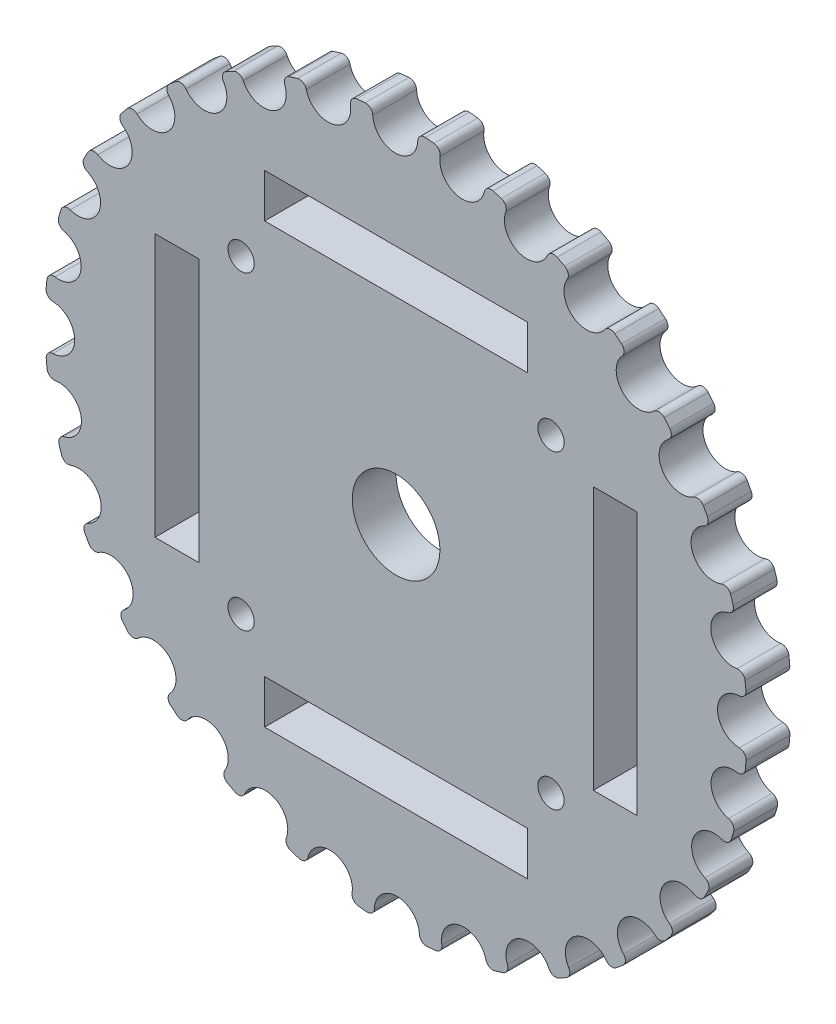
from build123d import *

# Parameters (mm, degrees)
SCHIZZO1_R                   = 40.062660939
ESTRUSIONE_ESTRUSIONE1_DEPTH = 5
SCHIZZO2_R                   = 2.57
TAGLIO_ESTRUSIONE1_DEPTH     = 6
RACCORDO1_R                  = 0.8
SCHIZZO3_R                   = 5
TAGLIO_ESTRUSIONE2_DEPTH     = 6.0000001
SCHIZZO4_R                   = 1.5
SCHIZZO4_W                   = 30
SCHIZZO4_H                   = 5
SCHIZZO4_W_2                 = 5
SCHIZZO4_H_2                 = 30
TAGLIO_ESTRUSIONE3_DEPTH     = 6.0000001


with BuildPart() as part:
    # Schizzo1 → Estrusione-Estrusione1 (new body)
    with BuildSketch(Plane.XY):
        Circle(SCHIZZO1_R)
    extrude(amount=ESTRUSIONE_ESTRUSIONE1_DEPTH)

    # Schizzo2 → Taglio-Estrusione1 (cut, through all)
    with BuildSketch(Plane.XY):
        with Locations((-0.093519434, 39.234888545)):
            Circle(SCHIZZO2_R)
        with Locations((7.562660721, 38.499613085)):
            Circle(SCHIZZO2_R)
        with Locations((14.928284395, 36.284819086)):
            Circle(SCHIZZO2_R)
        with Locations((21.7202948, 32.675619837)):
            Circle(SCHIZZO2_R)
        with Locations((27.677678787, 27.810714843)):
            Circle(SCHIZZO2_R)
        with Locations((32.571497429, 21.877059674)):
            Circle(SCHIZZO2_R)
        with Locations((36.21368402, 15.102681371)):
            Circle(SCHIZZO2_R)
        with Locations((38.464271373, 7.747915492)):
            Circle(SCHIZZO2_R)
        with Locations((39.236770677, 0.095401566)):
            Circle(SCHIZZO2_R)
        with Locations((38.501495217, -7.560778589)):
            Circle(SCHIZZO2_R)
        with Locations((36.286701218, -14.926402263)):
            Circle(SCHIZZO2_R)
        with Locations((32.677501969, -21.718412668)):
            Circle(SCHIZZO2_R)
        with Locations((27.812596975, -27.675796655)):
            Circle(SCHIZZO2_R)
        with Locations((21.878941807, -32.569615297)):
            Circle(SCHIZZO2_R)
        with Locations((15.104563503, -36.211801888)):
            Circle(SCHIZZO2_R)
        with Locations((7.749797624, -38.462389241)):
            Circle(SCHIZZO2_R)
        with Locations((0.097283698, -39.234888545)):
            Circle(SCHIZZO2_R)
        with Locations((-7.558896457, -38.499613085)):
            Circle(SCHIZZO2_R)
        with Locations((-14.92452013, -36.284819086)):
            Circle(SCHIZZO2_R)
        with Locations((-21.716530536, -32.675619837)):
            Circle(SCHIZZO2_R)
        with Locations((-27.673914523, -27.810714843)):
            Circle(SCHIZZO2_R)
        with Locations((-32.567733165, -21.877059674)):
            Circle(SCHIZZO2_R)
        with Locations((-36.209919756, -15.102681371)):
            Circle(SCHIZZO2_R)
        with Locations((-38.460507109, -7.747915492)):
            Circle(SCHIZZO2_R)
        with Locations((-39.233006413, -0.095401566)):
            Circle(SCHIZZO2_R)
        with Locations((-38.497730953, 7.560778589)):
            Circle(SCHIZZO2_R)
        with Locations((-36.282936953, 14.926402263)):
            Circle(SCHIZZO2_R)
        with Locations((-32.673737705, 21.718412668)):
            Circle(SCHIZZO2_R)
        with Locations((-27.808832711, 27.675796655)):
            Circle(SCHIZZO2_R)
        with Locations((-21.875177542, 32.569615297)):
            Circle(SCHIZZO2_R)
        with Locations((-15.100799239, 36.211801888)):
            Circle(SCHIZZO2_R)
        with Locations((-7.74603336, 38.462389241)):
            Circle(SCHIZZO2_R)
    extrude(amount=TAGLIO_ESTRUSIONE1_DEPTH, mode=Mode.SUBTRACT)

    # Raccordo1
    raccordo1_edges = [part.edges().sort_by_distance(p)[0] for p in [
        (31.942109789, -24.180951671, 2.5),
        (34.663171869, -20.086844389, 2.5),
        (26.611153993, -29.94767578, 2.5),
        (30.078524478, -26.463166227, 2.5),
        (20.257609847, -34.563652076, 2.5),
        (24.337986317, -31.822621255, 2.5),
        (13.125595942, -37.851493137, 2.5),
        (17.662122402, -35.959230161, 2.5),
        (5.489149667, -39.684833847, 2.5),
        (10.307451953, -38.713992764, 2.5),
        (-2.358297523, -39.993189849, 2.5),
        (2.556595149, -39.981003273, 2.5),
        (-10.115191512, -38.764670799, 2.5),
        (-5.292585413, -39.711526553, 2.5),
        (-17.483441203, -36.046443447, 2.5),
        (-12.938431635, -37.915877787, 2.5),
        (10.11906027, 38.763661086, 2.5),
        (-24.179873687, -31.942925821, 2.5),
        (-20.087085287, -34.663032271, 2.5),
        (5.296099227, 39.711058088, 2.5),
        (-29.947118726, -26.611780879, 2.5),
        (-26.46378579, -30.077979373, 2.5),
        (-34.563503922, -20.257862625, 2.5),
        (-31.823435482, -24.336921654, 2.5),
        (-37.85157961, -13.125346568, 2.5),
        (-35.960025392, -17.660503258, 2.5),
        (-39.684944931, -5.488346503, 2.5),
        (-38.714558233, -10.305327861, 2.5),
        (-39.993111736, 2.359621835, 2.5),
        (-39.981163224, -2.554092556, 2.5),
        (-38.764218427, 10.11692499, 2.5),
        (-39.711167015, 5.295282413, 2.5),
        (-36.045488681, 17.485409554, 2.5),
        (-37.914963935, 12.941109354, 2.5),
        (-31.941416979, 24.181866819, 2.5),
        (-34.661613715, 20.089533001, 2.5),
        (-26.609750631, 29.948922733, 2.5),
        (-30.076182583, 26.46582783, 2.5),
        (17.487042146, 36.044696676, 2.5),
        (-20.255423044, 34.564933659, 2.5),
        (-24.334930677, 31.824957981, 2.5),
        (12.941372162, 37.914874232, 2.5),
        (-13.122672082, 37.852506904, 2.5),
        (-17.658531673, 35.9609936, 2.5),
        (-5.485647344, 39.685318126, 2.5),
        (-10.303586252, 38.715021785, 2.5),
        (24.182945141, 31.940600586, 2.5),
        (20.089291397, 34.661753745, 2.5),
        (29.949479628, 26.60912384, 2.5),
        (26.465208159, 30.076727857, 2.5),
        (34.565081384, 20.255170956, 2.5),
        (31.824144106, 24.335995015, 2.5),
        (37.852420015, 13.122922714, 2.5),
        (35.960198926, 17.660149906, 2.5),
        (39.685206872, 5.486452137, 2.5),
        (38.714456796, 10.305708927, 2.5),
        (39.993041872, -2.360805648, 2.5),
        (39.981088796, 2.555257362, 2.5),
        (2.36213165, 39.992963576, 2.5),
        (38.764113933, -10.117325363, 2.5),
        (39.711417465, -5.293403861, 2.5),
        (-2.552756457, 39.981248554, 2.5),
        (36.045652002, -17.48507287, 2.5),
        (37.915787671, -12.938695713, 2.5),
    ]]
    fillet(raccordo1_edges, radius=RACCORDO1_R)

    # Schizzo3 → Taglio-Estrusione2 (cut, through all)
    with BuildSketch(Plane.XY):
        Circle(SCHIZZO3_R)
    extrude(amount=TAGLIO_ESTRUSIONE2_DEPTH, mode=Mode.SUBTRACT)

    # Schizzo4 → Taglio-Estrusione3 (cut, through all)
    with BuildSketch(Plane.XY):
        with Locations((17.673630121, 17.678291984)):
            Circle(SCHIZZO4_R)
        with Locations((17.673630121, -17.681708016)):
            Circle(SCHIZZO4_R)
        with Locations((-17.677047053, -17.681708016)):
            Circle(SCHIZZO4_R)
        with Locations((-17.677047053, 17.678291984)):
            Circle(SCHIZZO4_R)
        with Locations((0, 25)):
            Rectangle(SCHIZZO4_W, SCHIZZO4_H)
        with Locations((-25, 0)):
            Rectangle(SCHIZZO4_W_2, SCHIZZO4_H_2)
        with Locations((25, 0)):
            Rectangle(SCHIZZO4_W_2, SCHIZZO4_H_2)
        with Locations((0, -25)):
            Rectangle(SCHIZZO4_W, SCHIZZO4_H)
    extrude(amount=TAGLIO_ESTRUSIONE3_DEPTH, mode=Mode.SUBTRACT)


solid = part.part
